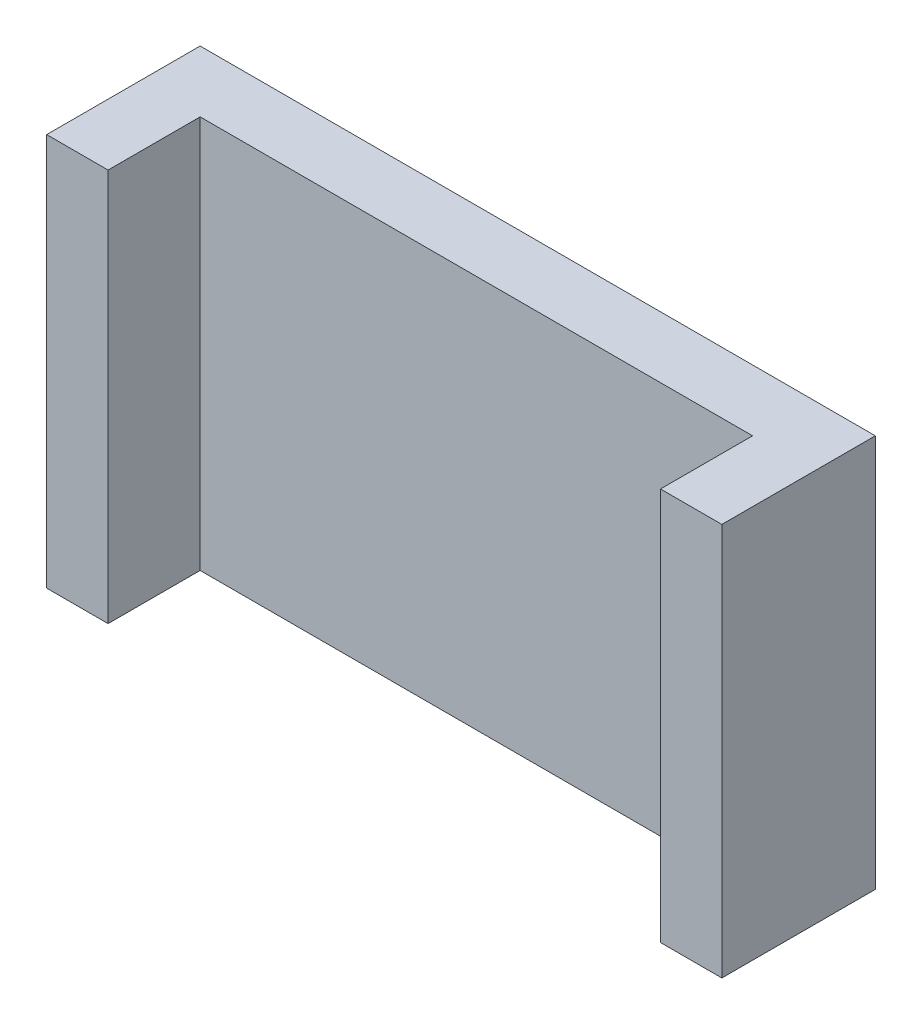
from build123d import *

# Parameters (mm, degrees)
SKETCH1_W           = 55
SKETCH1_H           = 32
BOSS_EXTRUDE1_DEPTH = 5
SKETCH2_W           = 5
SKETCH2_H           = 32
BOSS_EXTRUDE2_DEPTH = 7.5


with BuildPart() as part:
    # Sketch1 → Boss-Extrude1 (new body)
    with BuildSketch(Plane.XY):
        with Locations((27.5, 16)):
            Rectangle(SKETCH1_W, SKETCH1_H)
    extrude(amount=BOSS_EXTRUDE1_DEPTH)

    # Sketch2 → Boss-Extrude2 (add)
    with BuildSketch(Plane.XY.offset(5)):
        with Locations((2.5, 16)):
            Rectangle(SKETCH2_W, SKETCH2_H)
        with Locations((52.5, 16)):
            Rectangle(SKETCH2_W, SKETCH2_H)
    extrude(amount=BOSS_EXTRUDE2_DEPTH)


solid = part.part
